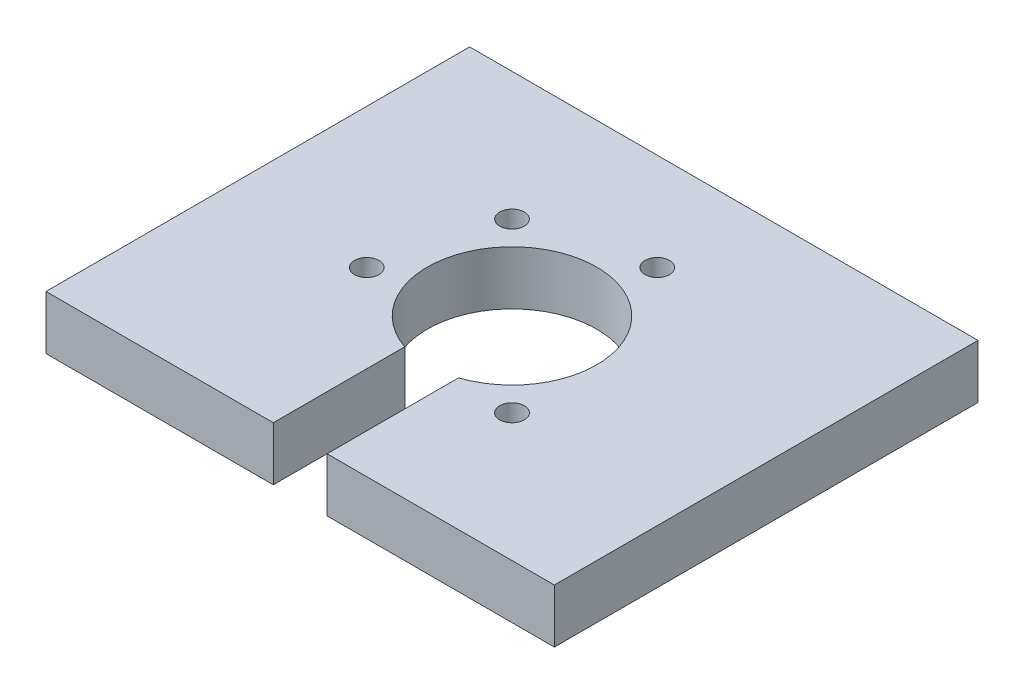
from build123d import *

# Parameters (mm, degrees)
SKETCH1_W                 = 60
SKETCH1_H                 = 50
BOSS_EXTRUDE1_DEPTH       = 6.35
CUT_EXTRUDE1_DEPTH        = 6.35
M3_5X0_6_TAPPED_HOLE1_D   = 2.9
M4X0_7_TAPPED_HOLE1_D     = 3.3
M4X0_7_TAPPED_HOLE1_DEPTH = 6.35
M4X0_7_TAPPED_HOLE1_TIP   = 0.991420021


with BuildPart() as part:
    # Sketch1 → Boss-Extrude1 (new body)
    with BuildSketch(Plane(origin=(0, 0, 0), x_dir=(1, 0, 0), z_dir=(0, 1, 0))):
        with Locations((-30, -25)):
            Rectangle(SKETCH1_W, SKETCH1_H)
    extrude(amount=BOSS_EXTRUDE1_DEPTH)

    # Sketch2 → Cut-Extrude1 (cut)
    with BuildSketch(Plane(origin=(0, 6.35, 0), x_dir=(1, 0, 0), z_dir=(0, 1, 0))):
        with BuildLine():
            Line((-26.825, -34.482582718), (-26.825, -20))
            Line((-26.825, -20), (-33.175, -20))
            Line((-33.175, -20), (-33.175, -34.482582718))
            ThreePointArc((-33.175, -34.482582718), (-30, -35), (-26.825, -34.482582718))
        make_face()
        with BuildLine():
            Line((-33.175, -20), (-26.825, -20))
            Line((-26.825, -20), (-26.825, -34.482582718))
            ThreePointArc((-26.825, -34.482582718), (-21.88365846, -30.841660723), (-20, -25))
            ThreePointArc((-20, -25), (-35.841660723, -16.88365846), (-33.175, -34.482582718))
            Line((-33.175, -34.482582718), (-33.175, -20))
        make_face()
        with BuildLine():
            Line((-26.825, -50), (-26.825, -34.482582718))
            ThreePointArc((-26.825, -34.482582718), (-30, -35), (-33.175, -34.482582718))
            Line((-33.175, -34.482582718), (-33.175, -50))
            Line((-33.175, -50), (-26.825, -50))
        make_face()
    extrude(amount=-CUT_EXTRUDE1_DEPTH, mode=Mode.SUBTRACT)

    # M3.5x0.6 Tapped Hole1 (through all)
    with Locations(Plane(origin=(-26.376533369, 6.35, 11.477038432), x_dir=(0, 0, 1), z_dir=(0, 1, 0))):
        with Locations((0, 0), (3.623466631, -13.522961568), (17.146428199, -17.146428199), (23.422456505, 6.276028306)):
            Hole(M3_5X0_6_TAPPED_HOLE1_D / 2)

    # M4x0.7 Tapped Hole1
    with Locations(Plane(origin=(-8, 3.175, 0), x_dir=(-1, 0, 0), z_dir=(0, 0, -1))):
        with Locations((0, 0), (22, 0), (44, 0)):
            Hole(M4X0_7_TAPPED_HOLE1_D / 2, depth=M4X0_7_TAPPED_HOLE1_DEPTH)
            with Locations((0, 0, -(M4X0_7_TAPPED_HOLE1_DEPTH + M4X0_7_TAPPED_HOLE1_TIP / 2))):  # 118° drill point
                Cone(0, M4X0_7_TAPPED_HOLE1_D / 2, M4X0_7_TAPPED_HOLE1_TIP, mode=Mode.SUBTRACT)


solid = part.part
